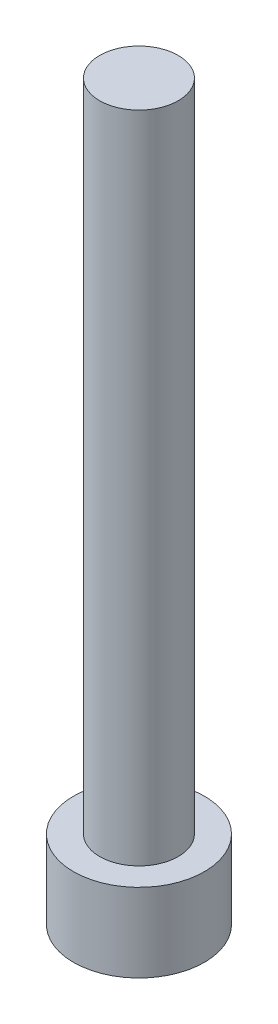
from build123d import *

# Parameters (mm, degrees)
SKETCH_1_R          = 2.5
EXTRUDE_1_DEPTH     = 3
SKETCH_2_R          = 1.5
EXTRUDE_2_DEPTH     = 25
CUT_EXTRUDE_1_DEPTH = 1.65


with BuildPart() as part:
    # 草图1 → 凸台-拉伸1 (new body)
    with BuildSketch(Plane(origin=(0, 0, 0), x_dir=(1, 0, 0), z_dir=(0, 1, 0))):
        Circle(SKETCH_1_R)
    extrude(amount=EXTRUDE_1_DEPTH)

    # 草图2 → 凸台-拉伸2 (add)
    with BuildSketch(Plane(origin=(0, 3, 0), x_dir=(1, 0, 0), z_dir=(0, 1, 0))):
        Circle(SKETCH_2_R)
    extrude(amount=EXTRUDE_2_DEPTH)

    # 草图3 → 切除-拉伸1 (cut)
    with BuildSketch(Plane.XZ):
        Polygon((1.425, 0), (0.7125, 1.2340862), (-0.7125, 1.2340862), (-1.425, 0), (-0.7125, -1.2340862), (0.7125, -1.2340862), align=None)
    extrude(amount=-CUT_EXTRUDE_1_DEPTH, mode=Mode.SUBTRACT)


solid = part.part
